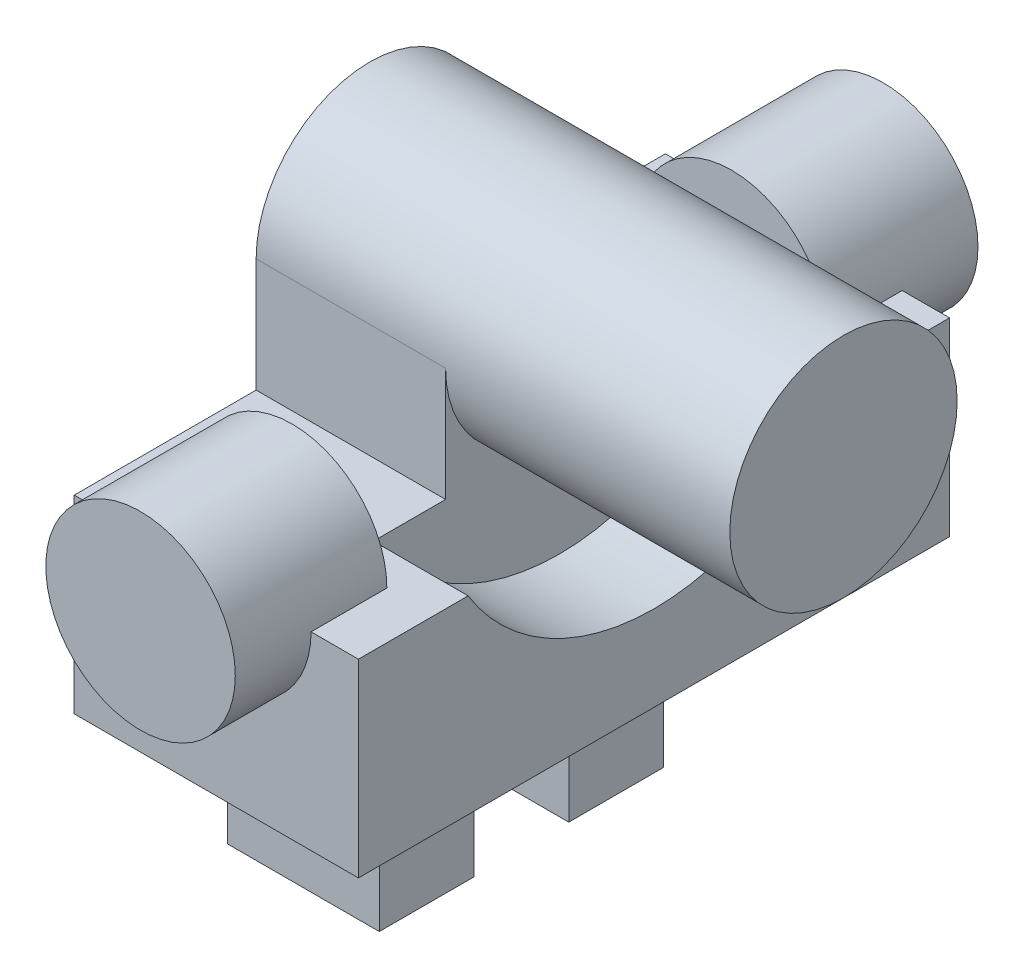
from build123d import *

# Parameters (mm, degrees)
CROQUIS2_R              = 6
SALIENTE_EXTRUIR1_DEPTH = 12.5
SALIENTE_EXTRUIR2_DEPTH = 15
CROQUIS5_R              = 11.5
CROQUIS5_R_2            = 6
CORTAR_EXTRUIR2_DEPTH   = 5
CROQUIS6_W              = 5
CROQUIS6_H              = 10
SALIENTE_EXTRUIR3_DEPTH = 8
CROQUIS7_R              = 1.7
CORTAR_EXTRUIR3_DEPTH   = 15
CROQUIS8_R              = 5
SALIENTE_EXTRUIR4_DEPTH = 4


with BuildPart() as part:
    # Croquis2 → Saliente-Extruir1 (new body, symmetric)
    with BuildSketch(Plane(origin=(0, 0, 0), x_dir=(0, 0, -1), z_dir=(1, 0, 0))):
        Circle(CROQUIS2_R)
    extrude(amount=SALIENTE_EXTRUIR1_DEPTH, both=True)

    # Croquis3 → Saliente-Extruir2 (add)
    with BuildSketch(Plane.ZY.offset(12.5)):
        Polygon((-15.6, -6), (-6, -6), (-6, 0), (6, 0), (6, -6), (15.6, -6), (15.6, -16), (-15.6, -16), align=None)
    extrude(amount=-SALIENTE_EXTRUIR2_DEPTH)

    # Croquis5 → Cortar-Extruir2 (cut)
    with BuildSketch(Plane(origin=(2.5, 0, 0), x_dir=(0, 0, -1), z_dir=(1, 0, 0))):
        Circle(CROQUIS5_R)
        Circle(CROQUIS5_R_2, mode=Mode.SUBTRACT)
    extrude(amount=-CORTAR_EXTRUIR2_DEPTH, mode=Mode.SUBTRACT)

    # Croquis6 → Saliente-Extruir3 (add)
    with BuildSketch(Plane.ZY.offset(12.5)):
        with Locations((5, -21)):
            Rectangle(CROQUIS6_W, CROQUIS6_H)
        with Locations((-5, -21)):
            Rectangle(CROQUIS6_W, CROQUIS6_H)
    extrude(amount=-SALIENTE_EXTRUIR3_DEPTH)

    # Croquis7 → Cortar-Extruir3 (cut)
    with BuildSketch(Plane.XY.offset(7.5)):
        with Locations((-8.5, -22.3)):
            Circle(CROQUIS7_R)
    extrude(amount=-CORTAR_EXTRUIR3_DEPTH, mode=Mode.SUBTRACT)

    # Croquis8 → Saliente-Extruir4 (add, symmetric)
    with BuildSketch(Plane.XY.offset(15.6)):
        with Locations((-5, -6)):
            Circle(CROQUIS8_R)
    saliente_extruir4 = extrude(amount=SALIENTE_EXTRUIR4_DEPTH, both=True)

    # Simetría1: Saliente-Extruir4 across plane
    add(saliente_extruir4.mirror(Plane.XY))


solid = part.part
